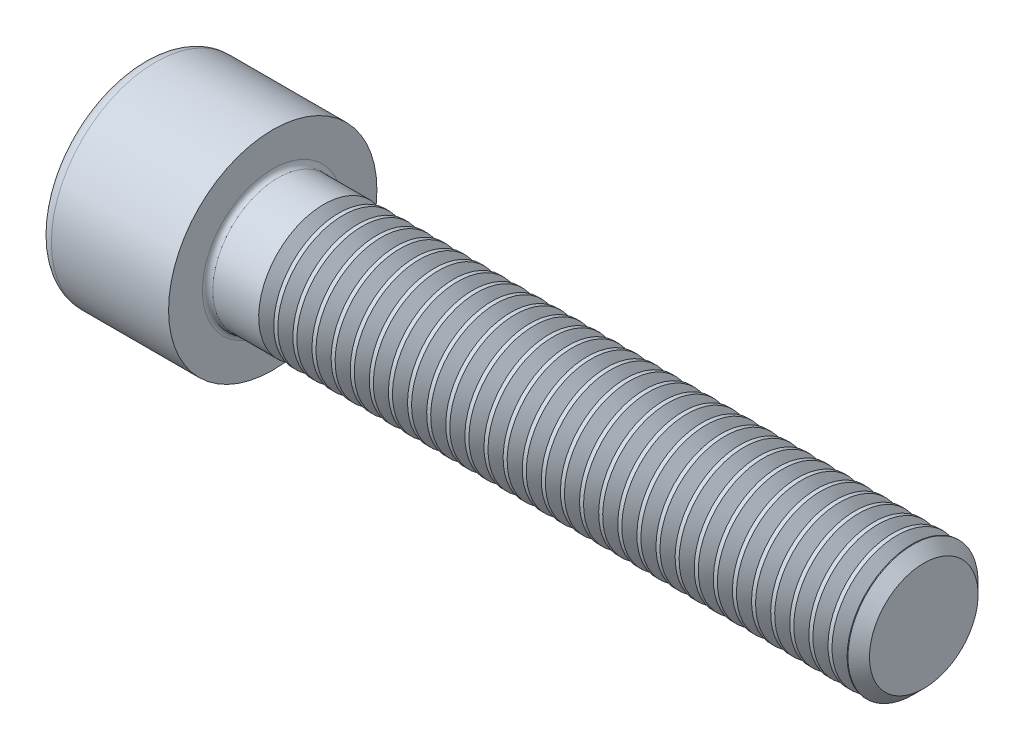
from build123d import *

# Parameters (mm, degrees)
FILLET1_R       = 0.4
FILLET2_R       = 1
HEX_2_DEPTH     = 5
THDSCHPAT_COUNT = 31
THDSCHPAT_PITCH = 1.467741935


with BuildPart() as part:
    # BodySke → Base-Revolve (revolve)
    with BuildSketch(Plane.XY, mode=Mode.PRIVATE) as base_revolve_sk:
        Polygon((0, 0), (0, 8), (10, 8), (10, 5), (59.172, 5), (60, 4.172), (60, 0), align=None)
    revolve(base_revolve_sk.sketch.rotate(Axis((-31.75, 0, 0), (1, 0, 0)), 90), axis=Axis((-31.75, 0, 0), (1, 0, 0)))  # turned: the seam where the file's is

    # Fillet1
    fillet1_edges = [part.edges().sort_by_distance(p)[0] for p in [
        (10, 0, -5),
    ]]
    fillet(fillet1_edges, radius=FILLET1_R)

    # Fillet2
    fillet2_edges = [part.edges().sort_by_distance(p)[0] for p in [
        (0, 0, -8),
    ]]
    fillet(fillet2_edges, radius=FILLET2_R)

    # Sketch2 → Hex-PreBroach (revolve, cut)
    with BuildSketch(Plane.XY, mode=Mode.PRIVATE) as hex_prebroach_sk:
        Polygon((0, 4.0125), (5, 4.0125), (7.316617955, 0), (0, 0), align=None)
    revolve(hex_prebroach_sk.sketch.rotate(Axis((0, 0, 0), (1, 0, 0)), 90), axis=Axis((0, 0, 0), (1, 0, 0)), mode=Mode.SUBTRACT)  # turned: the seam where the file's is

    # Sketch3 → Hex 2 (cut)
    with BuildSketch(Plane(origin=(0, 0, 0), x_dir=(0, 0.5, 0.866025404), z_dir=(-1, 0, 0))):
        Polygon((2.316617955, 4.0125), (-2.316617955, 4.0125), (-4.63323591, 0), (-2.316617955, -4.0125), (2.316617955, -4.0125), (4.63323591, 0), align=None)
    extrude(amount=-HEX_2_DEPTH, mode=Mode.SUBTRACT)

    # ThdSchSke → ThreadSchematic (revolve, cut)
    with BuildSketch(Plane.XY, mode=Mode.PRIVATE) as threadschematic_sk:
        Polygon((14.5, -4.172), (13.920228158, -5), (13.920228158, -6.25), (15.079771842, -6.25), (15.079771842, -5), align=None)
    threadschematic = revolve(threadschematic_sk.sketch.rotate(Axis((-3.175, 0, 0), (1, 0, 0)), 270), axis=Axis((-3.175, 0, 0), (1, 0, 0)), mode=Mode.SUBTRACT)  # turned: the seam where the file's is

    # ThdSchPat: ThreadSchematic ×31
    with Locations(*[(i * THDSCHPAT_PITCH, 0, 0) for i in range(1, THDSCHPAT_COUNT)]):
        add(threadschematic, mode=Mode.SUBTRACT)


solid = part.part
